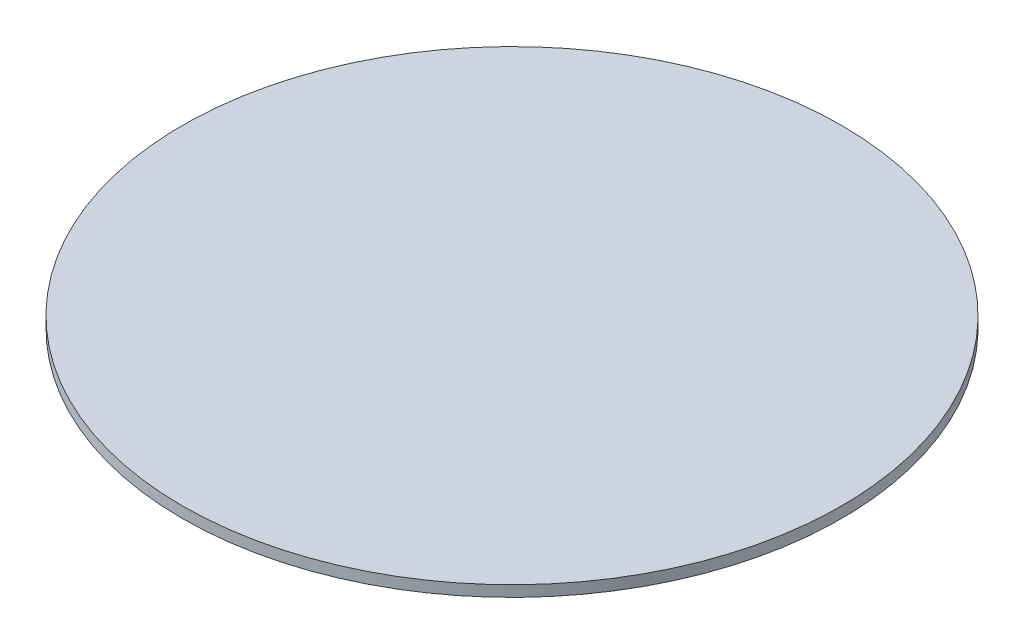
from build123d import *

# Parameters (mm, degrees)
SKETCH1_R           = 60
BOSS_EXTRUDE1_DEPTH = 2


with BuildPart() as part:
    # Sketch1 → Boss-Extrude1 (new body)
    with BuildSketch(Plane(origin=(0, 0, 0), x_dir=(1, 0, 0), z_dir=(0, 1, 0))):
        Circle(SKETCH1_R)
    extrude(amount=BOSS_EXTRUDE1_DEPTH)


solid = part.part
